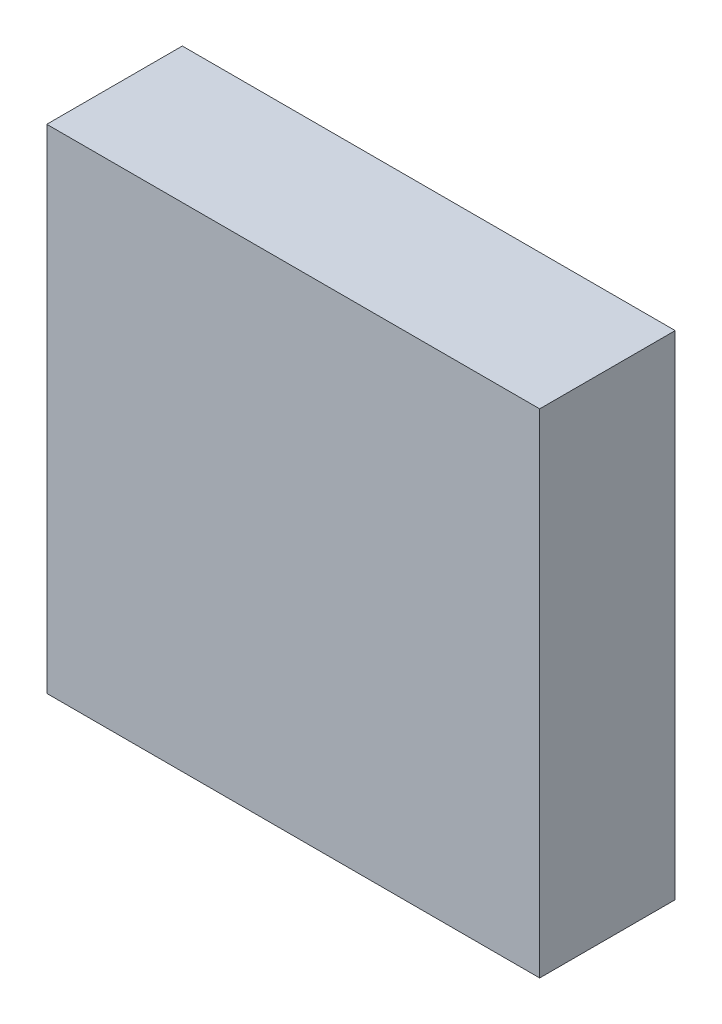
from build123d import *

# Parameters (mm, degrees)
SKETCH_1_W      = 4
SKETCH_1_H      = 4
EXTRUDE_1_DEPTH = 1.1


with BuildPart() as part:
    # Эскиз1 → Бобышка-Вытянуть1 (new body)
    with BuildSketch(Plane.XY):
        with Locations((2, 2)):
            Rectangle(SKETCH_1_W, SKETCH_1_H)
    extrude(amount=EXTRUDE_1_DEPTH)


solid = part.part
